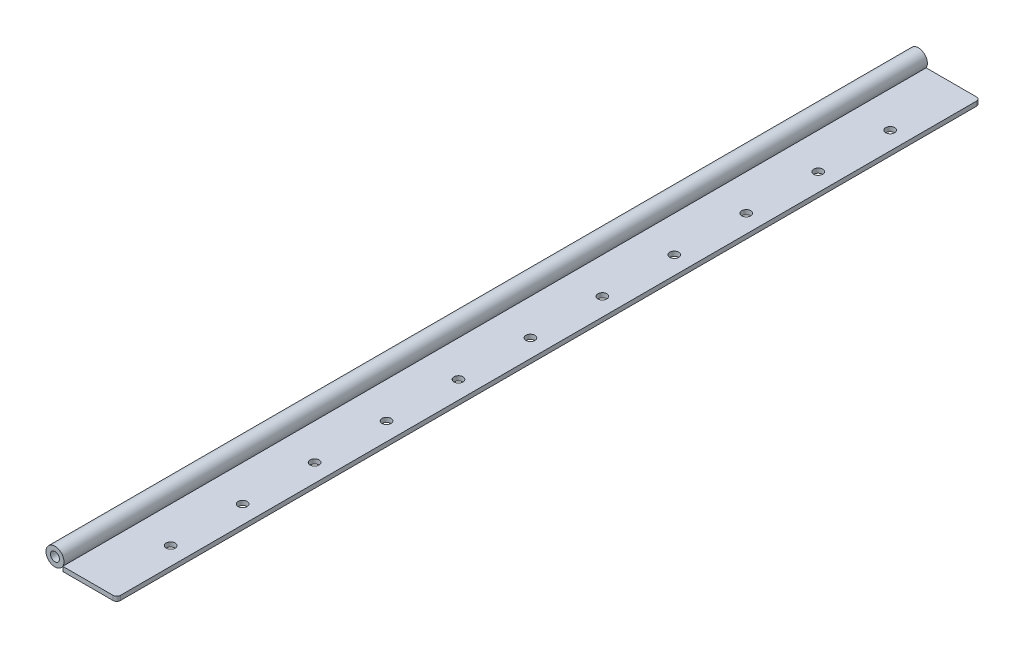
from build123d import *

# Parameters (mm, degrees)
SKETCH1_W           = 38.1
SKETCH1_H           = 609.6
BOSS_EXTRUDE1_DEPTH = 3.175
CUT_EXTRUDE1_REACH  = 5.175
SKETCH2_R           = 3.175
FILLET1_R           = 2.54
SKETCH3_R           = 6.35
SKETCH3_R_2         = 3.175
BOSS_EXTRUDE2_DEPTH = 609.6


with BuildPart() as part:
    # Sketch1 → Boss-Extrude1 (new body)
    with BuildSketch(Plane(origin=(0, 0, 0), x_dir=(1, 0, 0), z_dir=(0, 1, 0))):
        with Locations((19.05, 304.8)):
            Rectangle(SKETCH1_W, SKETCH1_H)
    extrude(amount=BOSS_EXTRUDE1_DEPTH)

    # Sketch2 → Cut-Extrude1 (cut, up to next)
    with BuildSketch(Plane(origin=(0, 3.175, 0), x_dir=(-1, 0, 0), z_dir=(0, 1, 0)), mode=Mode.PRIVATE) as cut_extrude1_sk1:
        with Locations((-25.4, -355.6)):
            Circle(SKETCH2_R)
    cut_extrude1_tool1 = extrude(cut_extrude1_sk1.sketch, amount=-CUT_EXTRUDE1_REACH, mode=Mode.PRIVATE) & part.part
    add(cut_extrude1_tool1.solids().sort_by_distance((25.4, 3.175, -355.6))[0], mode=Mode.SUBTRACT)
    # Sketch2 → Cut-Extrude1 (cut, up to next)
    with BuildSketch(Plane(origin=(0, 3.175, 0), x_dir=(-1, 0, 0), z_dir=(0, 1, 0)), mode=Mode.PRIVATE) as cut_extrude1_sk2:
        with Locations((-25.4, -304.8)):
            Circle(SKETCH2_R)
    cut_extrude1_tool2 = extrude(cut_extrude1_sk2.sketch, amount=-CUT_EXTRUDE1_REACH, mode=Mode.PRIVATE) & part.part
    add(cut_extrude1_tool2.solids().sort_by_distance((25.4, 3.175, -304.8))[0], mode=Mode.SUBTRACT)
    # Sketch2 → Cut-Extrude1 (cut, up to next)
    with BuildSketch(Plane(origin=(0, 3.175, 0), x_dir=(-1, 0, 0), z_dir=(0, 1, 0)), mode=Mode.PRIVATE) as cut_extrude1_sk3:
        with Locations((-25.4, -254)):
            Circle(SKETCH2_R)
    cut_extrude1_tool3 = extrude(cut_extrude1_sk3.sketch, amount=-CUT_EXTRUDE1_REACH, mode=Mode.PRIVATE) & part.part
    add(cut_extrude1_tool3.solids().sort_by_distance((25.4, 3.175, -254))[0], mode=Mode.SUBTRACT)
    # Sketch2 → Cut-Extrude1 (cut, up to next)
    with BuildSketch(Plane(origin=(0, 3.175, 0), x_dir=(-1, 0, 0), z_dir=(0, 1, 0)), mode=Mode.PRIVATE) as cut_extrude1_sk4:
        with Locations((-25.4, -406.4)):
            Circle(SKETCH2_R)
    cut_extrude1_tool4 = extrude(cut_extrude1_sk4.sketch, amount=-CUT_EXTRUDE1_REACH, mode=Mode.PRIVATE) & part.part
    add(cut_extrude1_tool4.solids().sort_by_distance((25.4, 3.175, -406.4))[0], mode=Mode.SUBTRACT)
    # Sketch2 → Cut-Extrude1 (cut, up to next)
    with BuildSketch(Plane(origin=(0, 3.175, 0), x_dir=(-1, 0, 0), z_dir=(0, 1, 0)), mode=Mode.PRIVATE) as cut_extrude1_sk5:
        with Locations((-25.4, -457.2)):
            Circle(SKETCH2_R)
    cut_extrude1_tool5 = extrude(cut_extrude1_sk5.sketch, amount=-CUT_EXTRUDE1_REACH, mode=Mode.PRIVATE) & part.part
    add(cut_extrude1_tool5.solids().sort_by_distance((25.4, 3.175, -457.2))[0], mode=Mode.SUBTRACT)
    # Sketch2 → Cut-Extrude1 (cut, up to next)
    with BuildSketch(Plane(origin=(0, 3.175, 0), x_dir=(-1, 0, 0), z_dir=(0, 1, 0)), mode=Mode.PRIVATE) as cut_extrude1_sk6:
        with Locations((-25.4, -508)):
            Circle(SKETCH2_R)
    cut_extrude1_tool6 = extrude(cut_extrude1_sk6.sketch, amount=-CUT_EXTRUDE1_REACH, mode=Mode.PRIVATE) & part.part
    add(cut_extrude1_tool6.solids().sort_by_distance((25.4, 3.175, -508))[0], mode=Mode.SUBTRACT)
    # Sketch2 → Cut-Extrude1 (cut, up to next)
    with BuildSketch(Plane(origin=(0, 3.175, 0), x_dir=(-1, 0, 0), z_dir=(0, 1, 0)), mode=Mode.PRIVATE) as cut_extrude1_sk7:
        with Locations((-25.4, -558.8)):
            Circle(SKETCH2_R)
    cut_extrude1_tool7 = extrude(cut_extrude1_sk7.sketch, amount=-CUT_EXTRUDE1_REACH, mode=Mode.PRIVATE) & part.part
    add(cut_extrude1_tool7.solids().sort_by_distance((25.4, 3.175, -558.8))[0], mode=Mode.SUBTRACT)
    # Sketch2 → Cut-Extrude1 (cut, up to next)
    with BuildSketch(Plane(origin=(0, 3.175, 0), x_dir=(-1, 0, 0), z_dir=(0, 1, 0)), mode=Mode.PRIVATE) as cut_extrude1_sk8:
        with Locations((-25.4, -101.6)):
            Circle(SKETCH2_R)
    cut_extrude1_tool8 = extrude(cut_extrude1_sk8.sketch, amount=-CUT_EXTRUDE1_REACH, mode=Mode.PRIVATE) & part.part
    add(cut_extrude1_tool8.solids().sort_by_distance((25.4, 3.175, -101.6))[0], mode=Mode.SUBTRACT)
    # Sketch2 → Cut-Extrude1 (cut, up to next)
    with BuildSketch(Plane(origin=(0, 3.175, 0), x_dir=(-1, 0, 0), z_dir=(0, 1, 0)), mode=Mode.PRIVATE) as cut_extrude1_sk9:
        with Locations((-25.4, -50.8)):
            Circle(SKETCH2_R)
    cut_extrude1_tool9 = extrude(cut_extrude1_sk9.sketch, amount=-CUT_EXTRUDE1_REACH, mode=Mode.PRIVATE) & part.part
    add(cut_extrude1_tool9.solids().sort_by_distance((25.4, 3.175, -50.8))[0], mode=Mode.SUBTRACT)
    # Sketch2 → Cut-Extrude1 (cut, up to next)
    with BuildSketch(Plane(origin=(0, 3.175, 0), x_dir=(-1, 0, 0), z_dir=(0, 1, 0)), mode=Mode.PRIVATE) as cut_extrude1_sk10:
        with Locations((-25.4, -203.2)):
            Circle(SKETCH2_R)
    cut_extrude1_tool10 = extrude(cut_extrude1_sk10.sketch, amount=-CUT_EXTRUDE1_REACH, mode=Mode.PRIVATE) & part.part
    add(cut_extrude1_tool10.solids().sort_by_distance((25.4, 3.175, -203.2))[0], mode=Mode.SUBTRACT)
    # Sketch2 → Cut-Extrude1 (cut, up to next)
    with BuildSketch(Plane(origin=(0, 3.175, 0), x_dir=(-1, 0, 0), z_dir=(0, 1, 0)), mode=Mode.PRIVATE) as cut_extrude1_sk11:
        with Locations((-25.4, -152.4)):
            Circle(SKETCH2_R)
    cut_extrude1_tool11 = extrude(cut_extrude1_sk11.sketch, amount=-CUT_EXTRUDE1_REACH, mode=Mode.PRIVATE) & part.part
    add(cut_extrude1_tool11.solids().sort_by_distance((25.4, 3.175, -152.4))[0], mode=Mode.SUBTRACT)

    # Fillet1
    fillet1_edges = [part.edges().sort_by_distance(p)[0] for p in [
        (38.1, 1.5875, -609.6),
        (38.1, 1.5875, 0),
    ]]
    fillet(fillet1_edges, radius=FILLET1_R)


with BuildPart() as body_2:
    # Sketch3 → Boss-Extrude2 (new body)
    with BuildSketch(Plane.XY):
        with Locations((-5.499261314, 6.35)):
            Circle(SKETCH3_R)
        with Locations((-5.499261314, 6.35)):
            Circle(SKETCH3_R_2, mode=Mode.SUBTRACT)
    extrude(amount=-BOSS_EXTRUDE2_DEPTH)


solid = Compound([part.part, body_2.part])
